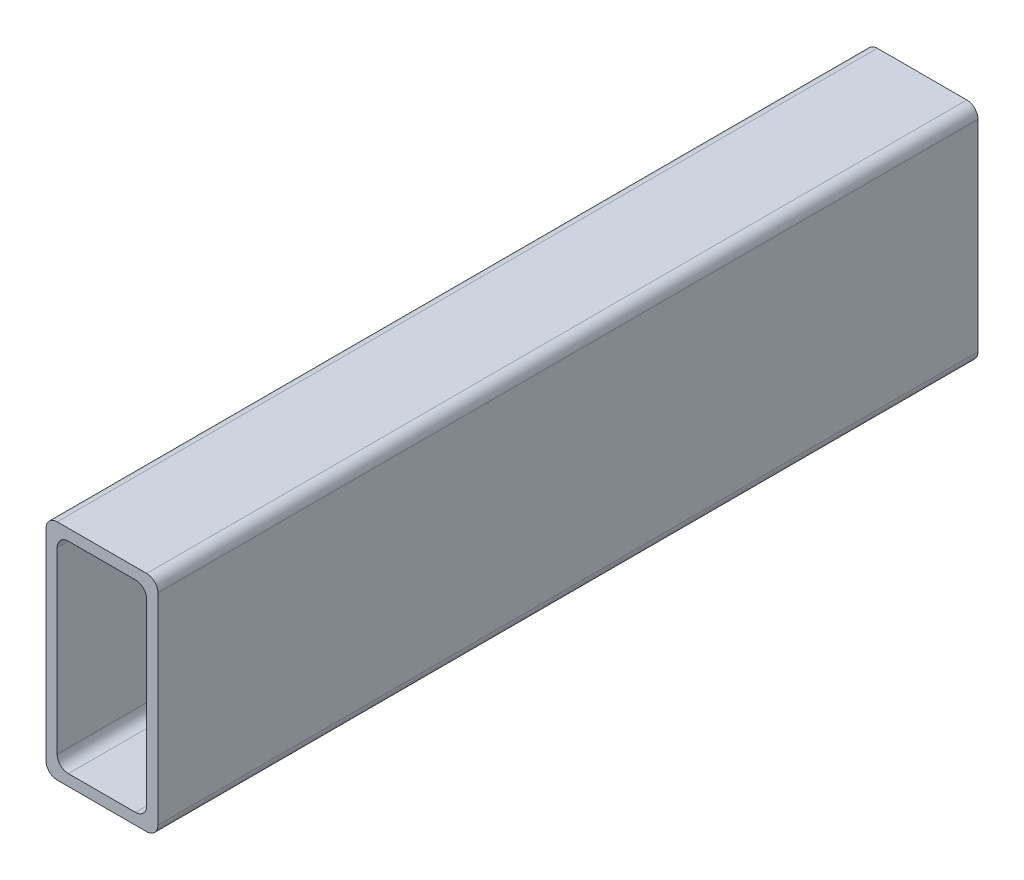
from build123d import *

# Parameters (mm, degrees)
DODANIE_WYCI_GNI_CIE1_DEPTH = 220


with BuildPart() as part:
    # Szkic1 → Dodanie-wyciągnięcie1 (new body)
    with BuildSketch(Plane.XY):
        with BuildLine():
            Line((-12, -30), (12, -30))
            ThreePointArc((12, -30), (14.121320344, -29.121320344), (15, -27))
            Line((15, -27), (15, 27))
            ThreePointArc((15, 27), (14.121320344, 29.121320344), (12, 30))
            Line((12, 30), (-12, 30))
            ThreePointArc((-12, 30), (-14.121320344, 29.121320344), (-15, 27))
            Line((-15, 27), (-15, -27))
            ThreePointArc((-15, -27), (-14.121320344, -29.121320344), (-12, -30))
        make_face()
        with BuildLine():
            Line((-9, 27), (9, 27))
            ThreePointArc((9, 27), (11.121320344, 26.121320344), (12, 24))
            Line((12, 24), (12, -24))
            ThreePointArc((12, -24), (11.121320344, -26.121320344), (9, -27))
            Line((9, -27), (-9, -27))
            ThreePointArc((-9, -27), (-11.121320344, -26.121320344), (-12, -24))
            Line((-12, -24), (-12, 24))
            ThreePointArc((-12, 24), (-11.121320344, 26.121320344), (-9, 27))
        make_face(mode=Mode.SUBTRACT)
    extrude(amount=DODANIE_WYCI_GNI_CIE1_DEPTH)


solid = part.part
